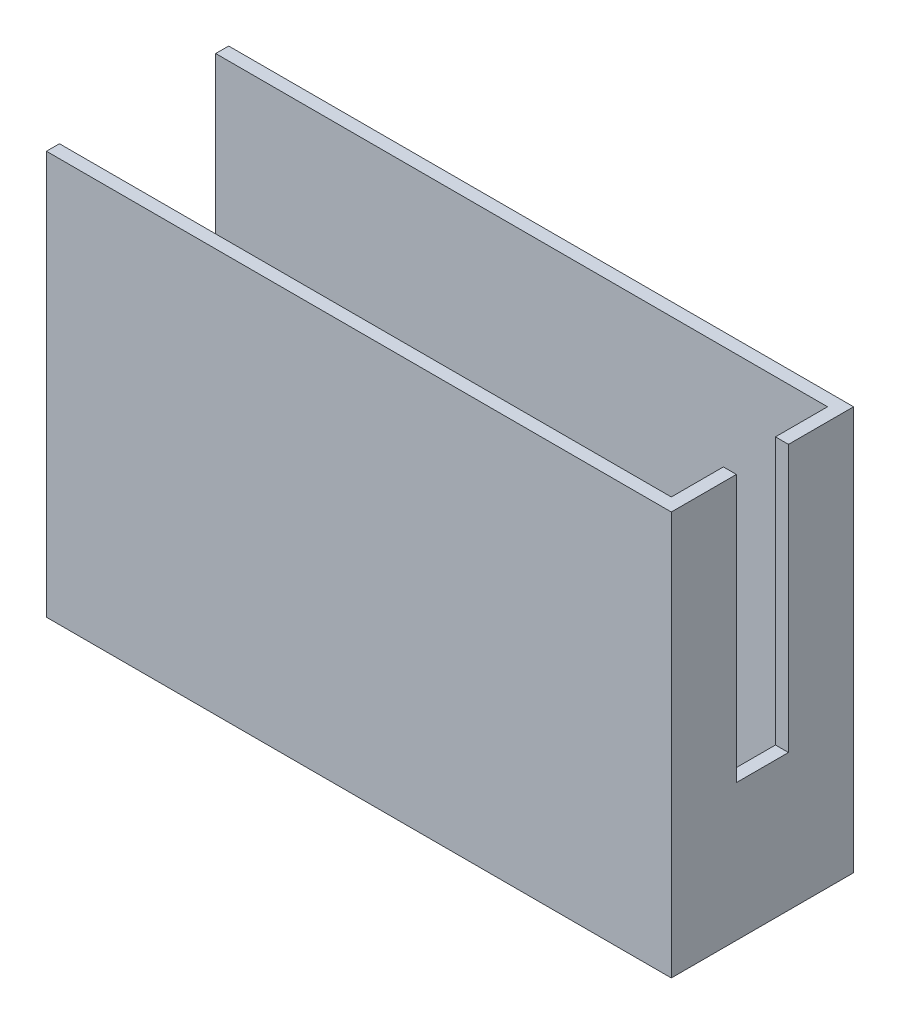
from build123d import *

# Parameters (mm, degrees)
SKETCH1_W           = 96
SKETCH1_H           = 28
BOSS_EXTRUDE1_DEPTH = 62
SKETCH2_W           = 92
SKETCH2_H           = 24
CUT_EXTRUDE1_DEPTH  = 60
SKETCH3_W           = 8
SKETCH3_H           = 41
CUT_EXTRUDE2_DEPTH  = 12
SKETCH4_W           = 24
SKETCH4_H           = 47
CUT_EXTRUDE3_DEPTH  = 10


with BuildPart() as part:
    # Sketch1 → Boss-Extrude1 (new body)
    with BuildSketch(Plane(origin=(0, 0, 0), x_dir=(1, 0, 0), z_dir=(0, 1, 0))):
        with Locations((48, 14)):
            Rectangle(SKETCH1_W, SKETCH1_H)
    extrude(amount=BOSS_EXTRUDE1_DEPTH)

    # Sketch2 → Cut-Extrude1 (cut)
    with BuildSketch(Plane(origin=(0, 62, 0), x_dir=(1, 0, 0), z_dir=(0, 1, 0))):
        with Locations((48, 14)):
            Rectangle(SKETCH2_W, SKETCH2_H)
    extrude(amount=-CUT_EXTRUDE1_DEPTH, mode=Mode.SUBTRACT)

    # Sketch3 → Cut-Extrude2 (cut)
    with BuildSketch(Plane(origin=(96, 0, 0), x_dir=(0, 0, -1), z_dir=(1, 0, 0))):
        with Locations((14, 41.5)):
            Rectangle(SKETCH3_W, SKETCH3_H)
    extrude(amount=-CUT_EXTRUDE2_DEPTH, mode=Mode.SUBTRACT)

    # Sketch4 → Cut-Extrude3 (cut)
    with BuildSketch(Plane.ZY):
        with Locations((-14, 38.5)):
            Rectangle(SKETCH4_W, SKETCH4_H)
    extrude(amount=-CUT_EXTRUDE3_DEPTH, mode=Mode.SUBTRACT)


solid = part.part
